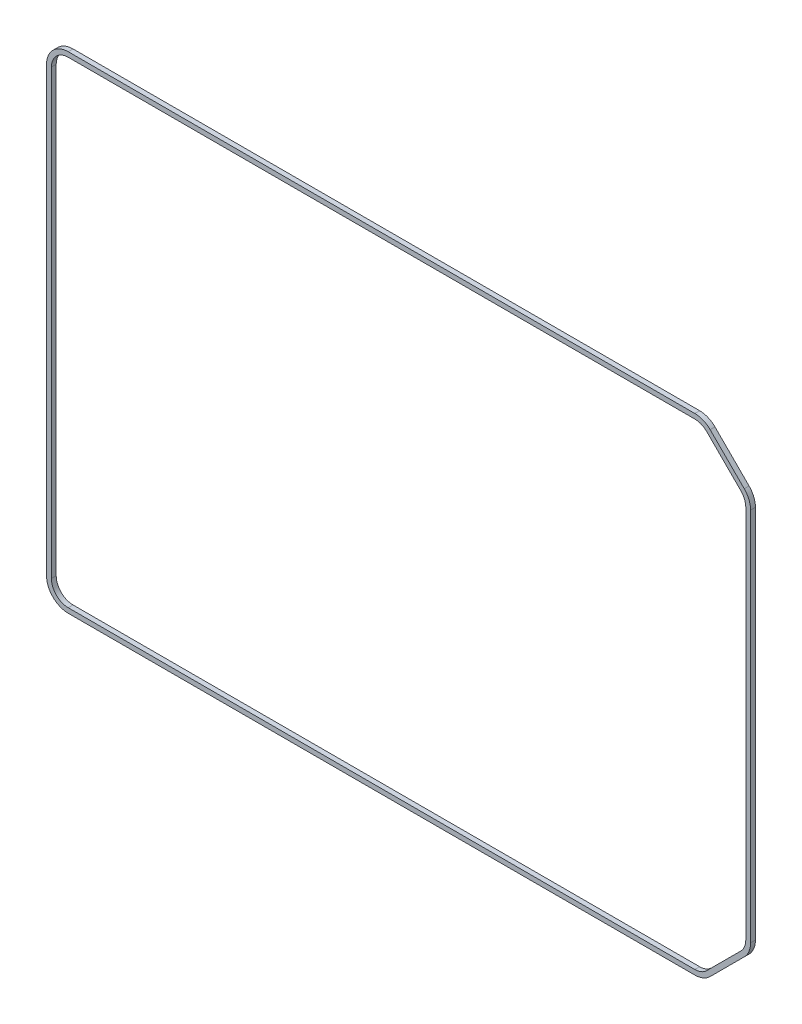
from build123d import *

# Parameters (mm, degrees)
BOSS_EXTRUDE1_DEPTH = 1


with BuildPart() as part:
    # Sketch1 → Boss-Extrude1 (new body)
    with BuildSketch(Plane.XY):
        with BuildLine():
            Line((-72.995, -45.925), (-72.995, 45.925))
            ThreePointArc((-72.995, 45.925), (-71.676980515, 49.106980515), (-68.495, 50.425))
            Line((-68.495, 50.425), (61.423932188, 50.425))
            ThreePointArc((61.423932188, 50.425), (63.146007634, 50.082457896), (64.605912703, 49.106980515))
            Line((64.605912703, 49.106980515), (71.676980515, 42.035912703))
            ThreePointArc((71.676980515, 42.035912703), (72.652457896, 40.576007634), (72.995, 38.853932188))
            Line((72.995, 38.853932188), (72.995, -38.853932188))
            ThreePointArc((72.995, -38.853932188), (72.652457896, -40.576007634), (71.676980515, -42.035912703))
            Line((71.676980515, -42.035912703), (64.605912703, -49.106980515))
            ThreePointArc((64.605912703, -49.106980515), (63.146007634, -50.082457896), (61.423932188, -50.425))
            Line((61.423932188, -50.425), (-68.495, -50.425))
            ThreePointArc((-68.495, -50.425), (-71.676980515, -49.106980515), (-72.995, -45.925))
        make_face()
        with BuildLine():
            Line((-71.995, 45.925), (-71.995, -45.925))
            ThreePointArc((-71.995, -45.925), (-70.969873734, -48.399873734), (-68.495, -49.425))
            Line((-68.495, -49.425), (61.423932188, -49.425))
            ThreePointArc((61.423932188, -49.425), (62.763324201, -49.158578364), (63.898805922, -48.399873734))
            Line((63.898805922, -48.399873734), (70.969873734, -41.328805922))
            ThreePointArc((70.969873734, -41.328805922), (71.728578364, -40.193324201), (71.995, -38.853932188))
            Line((71.995, -38.853932188), (71.995, 38.853932188))
            ThreePointArc((71.995, 38.853932188), (71.728578364, 40.193324201), (70.969873734, 41.328805922))
            Line((70.969873734, 41.328805922), (63.898805922, 48.399873734))
            ThreePointArc((63.898805922, 48.399873734), (62.763324201, 49.158578364), (61.423932188, 49.425))
            Line((61.423932188, 49.425), (-68.495, 49.425))
            ThreePointArc((-68.495, 49.425), (-70.969873734, 48.399873734), (-71.995, 45.925))
        make_face(mode=Mode.SUBTRACT)
    extrude(amount=BOSS_EXTRUDE1_DEPTH)


solid = part.part
